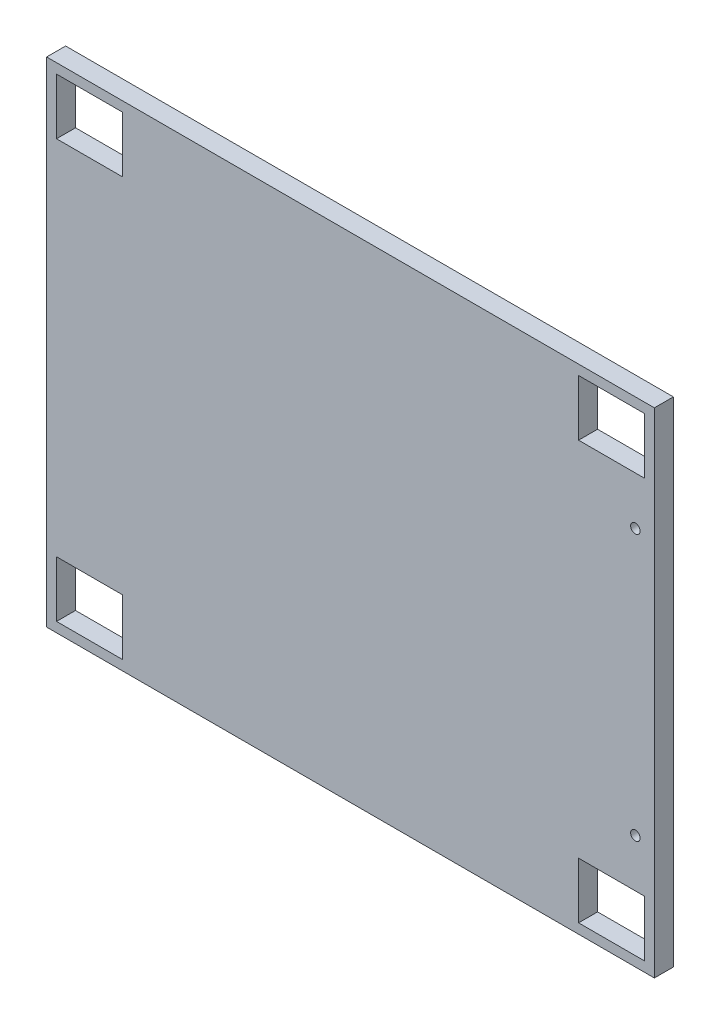
from build123d import *

# Parameters (mm, degrees)
SKETCH1_W           = 203.2
SKETCH1_H           = 165.1
SKETCH1_R           = 1.5875
SKETCH1_W_2         = 22.0345
SKETCH1_H_2         = 18.7325
BOSS_EXTRUDE1_DEPTH = 6.35


with BuildPart() as part:
    # Sketch1 → Boss-Extrude1 (new body)
    with BuildSketch(Plane.XY):
        with Locations((-29.151775306, -7.158362635)):
            Rectangle(SKETCH1_W, SKETCH1_H)
        with Locations((66.098224694, 37.291637365)):
            Circle(SKETCH1_R, mode=Mode.SUBTRACT)
        with Locations((66.098224694, -51.608362635)):
            Circle(SKETCH1_R, mode=Mode.SUBTRACT)
        with Locations((58.128974694, 62.723387365)):
            Rectangle(SKETCH1_W_2, SKETCH1_H_2, mode=Mode.SUBTRACT)
        with Locations((-116.432525306, 62.723387365)):
            Rectangle(SKETCH1_W_2, SKETCH1_H_2, mode=Mode.SUBTRACT)
        with Locations((58.128974694, -77.040112635)):
            Rectangle(SKETCH1_W_2, SKETCH1_H_2, mode=Mode.SUBTRACT)
        with Locations((-116.432525306, -77.040112635)):
            Rectangle(SKETCH1_W_2, SKETCH1_H_2, mode=Mode.SUBTRACT)
    extrude(amount=BOSS_EXTRUDE1_DEPTH)


solid = part.part
